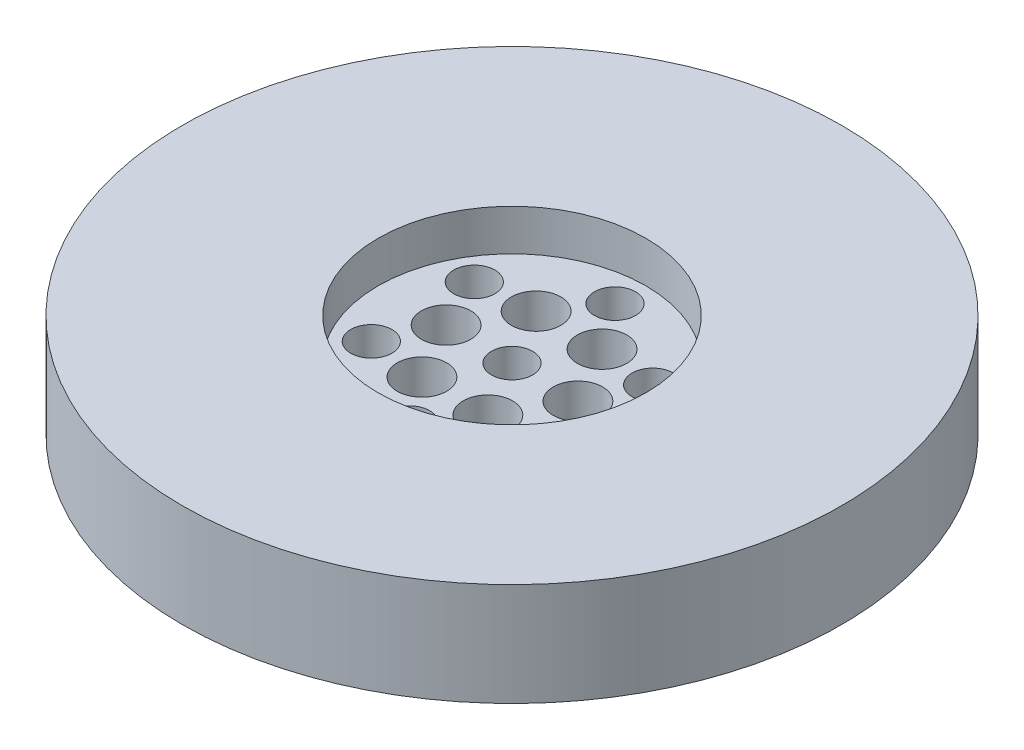
from build123d import *

# Parameters (mm, degrees)
SKETCH1_R           = 16
BOSS_EXTRUDE1_DEPTH = 5
SKETCH2_R           = 6.5
CUT_EXTRUDE2_DEPTH  = 2
SKETCH3_R           = 1
CUT_EXTRUDE3_DEPTH  = 3
SKETCH4_R           = 1.2
CUT_EXTRUDE4_DEPTH  = 3
SKETCH6_R           = 1
CUT_EXTRUDE6_DEPTH  = 3
CIRPATTERN3_COUNT   = 6
CIRPATTERN5_COUNT   = 6


with BuildPart() as part:
    # Sketch1 → Boss-Extrude1 (new body)
    with BuildSketch(Plane(origin=(0, 0, 0), x_dir=(1, 0, 0), z_dir=(0, 1, 0))):
        Circle(SKETCH1_R)
    extrude(amount=BOSS_EXTRUDE1_DEPTH)

    # Sketch2 → Cut-Extrude2 (cut)
    with BuildSketch(Plane(origin=(0, 5, 0), x_dir=(1, 0, 0), z_dir=(0, 1, 0))):
        Circle(SKETCH2_R)
    extrude(amount=-CUT_EXTRUDE2_DEPTH, mode=Mode.SUBTRACT)

    # Sketch3 → Cut-Extrude3 (cut)
    with BuildSketch(Plane(origin=(0, 3, 0), x_dir=(1, 0, 0), z_dir=(0, 1, 0))):
        Circle(SKETCH3_R)
    extrude(amount=-CUT_EXTRUDE3_DEPTH, mode=Mode.SUBTRACT)

    # Sketch4 → Cut-Extrude4 (cut)
    with BuildSketch(Plane(origin=(0, 3, 0), x_dir=(1, 0, 0), z_dir=(0, 1, 0))):
        with Locations((3.2, 0)):
            Circle(SKETCH4_R)
    cut_extrude4 = extrude(amount=-CUT_EXTRUDE4_DEPTH, mode=Mode.SUBTRACT)

    # Sketch6 → Cut-Extrude6 (cut)
    with BuildSketch(Plane(origin=(0, 3, 0), x_dir=(1, 0, 0), z_dir=(0, 1, 0))):
        with Locations((0, 5)):
            Circle(SKETCH6_R)
    cut_extrude6 = extrude(amount=-CUT_EXTRUDE6_DEPTH, mode=Mode.SUBTRACT)

    # CirPattern3: Cut-Extrude6 ×6 about axis
    cirpattern3_axis = Axis((0, 0, 0), (0, 1, 0))
    for i in range(1, CIRPATTERN3_COUNT):
        add(cut_extrude6.rotate(cirpattern3_axis, i * 360 / CIRPATTERN3_COUNT), mode=Mode.SUBTRACT)

    # CirPattern5: Cut-Extrude4 ×6 about axis
    cirpattern5_axis = Axis((0, 0, 0), (0, 1, 0))
    for i in range(1, CIRPATTERN5_COUNT):
        add(cut_extrude4.rotate(cirpattern5_axis, i * 360 / CIRPATTERN5_COUNT), mode=Mode.SUBTRACT)


solid = part.part
